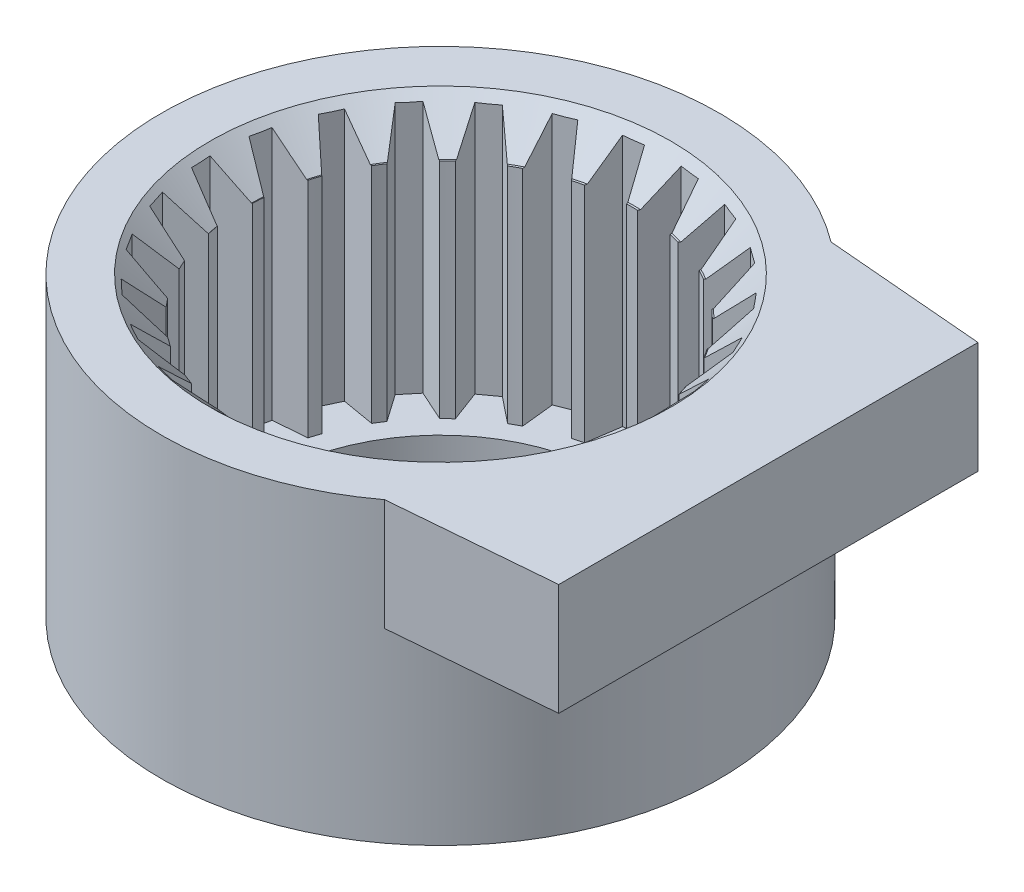
from build123d import *

# Parameters (mm, degrees)
BOSS_EXTRUDE1_DEPTH = 1.5
SKETCH2_R           = 3.75
BOSS_EXTRUDE2_DEPTH = 2.5
CUT_EXTRUDE1_DEPTH  = 3.5


with BuildPart() as part:
    # Sketch1 → Boss-Extrude1 (new body)
    with BuildSketch(Plane(origin=(0, 4, 0), x_dir=(1, 0, 0), z_dir=(0, 1, 0))):
        with BuildLine():
            Line((2.25, -3), (4.407767894, -2.817669075))
            Line((4.407767894, -2.817669075), (4.407767894, 2.817669075))
            Line((4.407767894, 2.817669075), (2.25, 3))
            ThreePointArc((2.25, 3), (-3.75, 0), (2.25, -3))
        make_face()
    extrude(amount=-BOSS_EXTRUDE1_DEPTH)

    # Sketch2 → Boss-Extrude2 (add)
    with BuildSketch(Plane.XZ.offset(-2.5)):
        Circle(SKETCH2_R)
    extrude(amount=BOSS_EXTRUDE2_DEPTH)

    # Sketch3 → Cut-Revolve1 (revolve, cut)
    with BuildSketch(Plane(origin=(0, 0, 0), x_dir=(-1, 0, 0), z_dir=(0, 0, -1))):
        Polygon((-2.3, 0), (0, 0), (0, 4), (-2.3, 4), (-2.3, 3), (-1.25, 3), (-1.25, 2.5), (-2.3, 2.5), align=None)
    revolve(axis=Axis((0, 0, 0), (0, 1, 0)), mode=Mode.SUBTRACT)

    # Sketch5 → Cut-Extrude1 (cut)
    with BuildSketch(Plane(origin=(0, 4, 0), x_dir=(1, 0, 0), z_dir=(0, 1, 0))):
        with BuildLine():
            Line((-2.529067321, -0.587880314), (-2.902560355, -0.834868575))
            Line((-2.902560355, -0.834868575), (-2.820708552, -1.086782523))
            Line((-2.820708552, -1.086782523), (-2.373370282, -1.067066526))
            ThreePointArc((-2.373370282, -1.067066526), (-2.342756688, -1.134609387), (-2.310227858, -1.201251007))
            Line((-2.310227858, -1.201251007), (-2.61056344, -1.533363619))
            Line((-2.61056344, -1.533363619), (-2.46863471, -1.757007511))
            Line((-2.46863471, -1.757007511), (-2.040253564, -1.626662424))
            ThreePointArc((-2.040253564, -1.626662424), (-1.993804525, -1.684470011), (-1.945724551, -1.740928371))
            Line((-1.945724551, -1.740928371), (-2.15403149, -2.137297476))
            Line((-2.15403149, -2.137297476), (-1.960943738, -2.318618944))
            Line((-1.960943738, -2.318618944), (-1.578436478, -2.085834829))
            ThreePointArc((-1.578436478, -2.085834829), (-1.51907056, -2.130274879), (-1.458460484, -2.173002492))
            Line((-1.458460484, -2.173002492), (-1.561650089, -2.608722762))
            Line((-1.561650089, -2.608722762), (-1.329535728, -2.736328711))
            Line((-1.329535728, -2.736328711), (-1.016936693, -2.41573225))
            ThreePointArc((-1.016936693, -2.41573225), (-0.948384073, -2.44401243), (-0.879052248, -2.470324564))
            Line((-0.879052248, -2.470324564), (-0.870640738, -2.918018091))
            Line((-0.870640738, -2.918018091), (-0.614084367, -2.983890571))
            Line((-0.614084367, -2.983890571), (-0.391035303, -2.595626018))
            ThreePointArc((-0.391035303, -2.595626018), (-0.317603395, -2.605969381), (-0.243906195, -2.614212747))
            Line((-0.243906195, -2.614212747), (-0.124422095, -3.045749301))
            Line((-0.124422095, -3.045749301), (0.140455905, -3.045749301))
            Line((0.140455905, -3.045749301), (0.259940005, -2.614212747))
            ThreePointArc((0.259940005, -2.614212747), (0.333637204, -2.605969381), (0.407069112, -2.595626018))
            Line((0.407069112, -2.595626018), (0.630118177, -2.983890571))
            Line((0.630118177, -2.983890571), (0.886674547, -2.918018091))
            Line((0.886674547, -2.918018091), (0.895086058, -2.470324564))
            ThreePointArc((0.895086058, -2.470324564), (0.964417882, -2.44401243), (1.032970502, -2.41573225))
            Line((1.032970502, -2.41573225), (1.345569538, -2.736328711))
            Line((1.345569538, -2.736328711), (1.577683899, -2.608722762))
            Line((1.577683899, -2.608722762), (1.474494293, -2.173002492))
            ThreePointArc((1.474494293, -2.173002492), (1.535104369, -2.130274879), (1.594470288, -2.085834829))
            Line((1.594470288, -2.085834829), (1.976977548, -2.318618944))
            Line((1.976977548, -2.318618944), (2.1700653, -2.137297476))
            Line((2.1700653, -2.137297476), (1.961758361, -1.740928371))
            ThreePointArc((1.961758361, -1.740928371), (2.009838335, -1.684470011), (2.056287373, -1.626662424))
            Line((2.056287373, -1.626662424), (2.484668519, -1.757007511))
            Line((2.484668519, -1.757007511), (2.626597249, -1.533363619))
            Line((2.626597249, -1.533363619), (2.326261668, -1.201251007))
            ThreePointArc((2.326261668, -1.201251007), (2.358790498, -1.134609387), (2.389404092, -1.067066526))
            Line((2.389404092, -1.067066526), (2.836742361, -1.086782523))
            Line((2.836742361, -1.086782523), (2.918594165, -0.834868575))
            Line((2.918594165, -0.834868575), (2.54510113, -0.587880314))
            ThreePointArc((2.54510113, -0.587880314), (2.56003491, -0.515242772), (2.572889495, -0.442208603))
            Line((2.572889495, -0.442208603), (3.01107698, -0.350056682))
            Line((3.01107698, -0.350056682), (3.027708807, -0.085701358))
            Line((3.027708807, -0.085701358), (2.60452626, 0.060643372))
            ThreePointArc((2.60452626, 0.060643372), (2.600926646, 0.134712752), (2.595214521, 0.208649224))
            Line((2.595214521, 0.208649224), (2.996718289, 0.406878819))
            Line((2.996718289, 0.406878819), (2.947085101, 0.667065102))
            Line((2.947085101, 0.667065102), (2.500803158, 0.703570923))
            ThreePointArc((2.500803158, 0.703570923), (2.478896326, 0.77441809), (2.454976405, 0.844611164))
            Line((2.454976405, 0.844611164), (2.794568499, 1.136462938))
            Line((2.794568499, 1.136462938), (2.681788931, 1.376131718))
            Line((2.681788931, 1.376131718), (2.240449127, 1.300504836))
            ThreePointArc((2.240449127, 1.300504836), (2.201611565, 1.363678201), (2.160986825, 1.425717388))
            Line((2.160986825, 1.425717388), (2.417329423, 1.792853222))
            Line((2.417329423, 1.792853222), (2.248489832, 1.996945229))
            Line((2.248489832, 1.996945229), (1.83982317, 1.813937558))
            ThreePointArc((1.83982317, 1.813937558), (1.786495184, 1.865467707), (1.731718227, 1.915454857))
            Line((1.731718227, 1.915454857), (1.888704382, 2.334806255))
            Line((1.888704382, 2.334806255), (1.674413578, 2.490497637))
            Line((1.674413578, 2.490497637), (1.324098088, 2.211608223))
            ThreePointArc((1.324098088, 2.211608223), (1.259630472, 2.248257326), (1.194143135, 2.283051563))
            Line((1.194143135, 2.283051563), (1.241908829, 2.728269135))
            Line((1.241908829, 2.728269135), (0.995631493, 2.82577723))
            Line((0.995631493, 2.82577723), (0.725678786, 2.46852972))
            ThreePointArc((0.725678786, 2.46852972), (0.654122277, 2.487994981), (0.58203937, 2.505410054))
            Line((0.58203937, 2.505410054), (0.517583309, 2.948519142))
            Line((0.517583309, 2.948519142), (0.254793951, 2.981717158))
            Line((0.254793951, 2.981717158), (0.082166147, 2.568558727))
            ThreePointArc((0.082166147, 2.568558727), (0.008016905, 2.569617071), (-0.066132338, 2.568558727))
            Line((-0.066132338, 2.568558727), (-0.238760142, 2.981717158))
            Line((-0.238760142, 2.981717158), (-0.5015495, 2.948519142))
            Line((-0.5015495, 2.948519142), (-0.56600556, 2.505410054))
            ThreePointArc((-0.56600556, 2.505410054), (-0.638088467, 2.487994981), (-0.709644976, 2.46852972))
            Line((-0.709644976, 2.46852972), (-0.979597684, 2.82577723))
            Line((-0.979597684, 2.82577723), (-1.22587502, 2.728269135))
            Line((-1.22587502, 2.728269135), (-1.178109325, 2.283051563))
            ThreePointArc((-1.178109325, 2.283051563), (-1.243596663, 2.248257326), (-1.308064279, 2.211608223))
            Line((-1.308064279, 2.211608223), (-1.658379769, 2.490497637))
            Line((-1.658379769, 2.490497637), (-1.872670572, 2.334806255))
            Line((-1.872670572, 2.334806255), (-1.715684417, 1.915454857))
            ThreePointArc((-1.715684417, 1.915454857), (-1.770461375, 1.865467707), (-1.823789361, 1.813937558))
            Line((-1.823789361, 1.813937558), (-2.232456022, 1.996945229))
            Line((-2.232456022, 1.996945229), (-2.401295614, 1.792853222))
            Line((-2.401295614, 1.792853222), (-2.144953016, 1.425717388))
            ThreePointArc((-2.144953016, 1.425717388), (-2.185577756, 1.363678201), (-2.224415318, 1.300504836))
            Line((-2.224415318, 1.300504836), (-2.665755122, 1.376131718))
            Line((-2.665755122, 1.376131718), (-2.778534689, 1.136462938))
            Line((-2.778534689, 1.136462938), (-2.438942596, 0.844611164))
            ThreePointArc((-2.438942596, 0.844611164), (-2.462862517, 0.77441809), (-2.484769348, 0.703570923))
            Line((-2.484769348, 0.703570923), (-2.931051292, 0.667065102))
            Line((-2.931051292, 0.667065102), (-2.980684479, 0.406878819))
            Line((-2.980684479, 0.406878819), (-2.579180711, 0.208649224))
            ThreePointArc((-2.579180711, 0.208649224), (-2.584892836, 0.134712752), (-2.58849245, 0.060643372))
            Line((-2.58849245, 0.060643372), (-3.011674997, -0.085701358))
            Line((-3.011674997, -0.085701358), (-2.99504317, -0.350056682))
            Line((-2.99504317, -0.350056682), (-2.556855686, -0.442208603))
            ThreePointArc((-2.556855686, -0.442208603), (-2.544001101, -0.515242772), (-2.529067321, -0.587880314))
        make_face()
    extrude(amount=-CUT_EXTRUDE1_DEPTH, mode=Mode.SUBTRACT)

    # Sketch8 → Cut-Revolve2 (revolve, cut)
    with BuildSketch(Plane.XY):
        Polygon((3.098036372, 4), (0, 4), (0, 3.5), (2.598036372, 3.5), align=None)
    revolve(axis=Axis((0, 0, 0), (0, 1, 0)), mode=Mode.SUBTRACT)


solid = part.part
